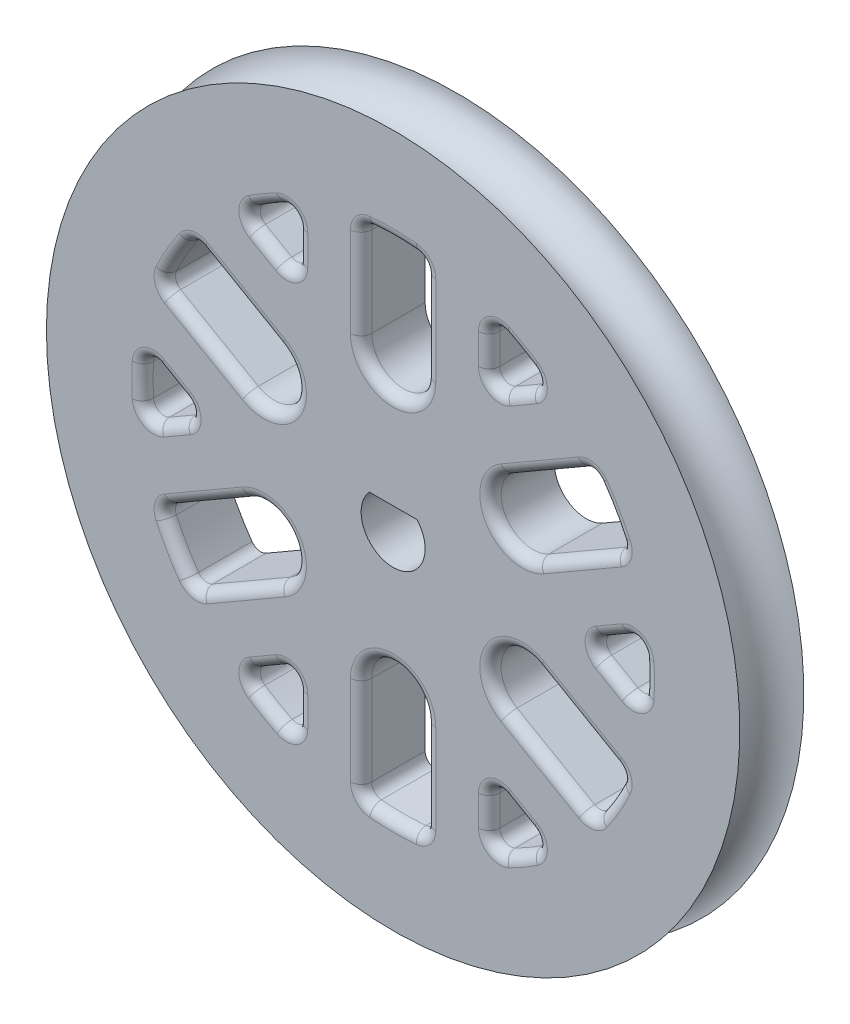
from build123d import *

# Parameters (mm, degrees)
CUT_EXTRUDE2_DEPTH       = 3
CUT_EXTRUDE1_DEPTH       = 4
FILLET2_R                = 0.5
FILLET3_R                = 0.5
CIRPATTERN1_COUNT        = 6
FILLET2_OF_CIRPATTERN1_R = 0.5
FILLET3_OF_CIRPATTERN1_R = 0.5


with BuildPart() as part:
    # Sketch3 → Revolve1 (revolve)
    with BuildSketch(Plane(origin=(0, 0, 0), x_dir=(1, 0, 0), z_dir=(0, 1, 0))):
        with BuildLine():
            Line((0, 1.5), (0, -1.5))
            Line((0, -1.5), (-16.25, -1.5))
            ThreePointArc((-16.25, -1.5), (-14.75, 0), (-16.25, 1.5))
            Line((-16.25, 1.5), (0, 1.5))
        make_face()
    revolve(axis=Axis((0, 0, -1.5), (0, 0, 1)))

    # Sketch6 → Cut-Extrude2 (cut)
    with BuildSketch(Plane.XY.offset(1.5)):
        with BuildLine():
            Line((-1.118033989, 1), (1.118033989, 1))
            ThreePointArc((1.118033989, 1), (0, -1.5), (-1.118033989, 1))
        make_face()
    extrude(amount=-CUT_EXTRUDE2_DEPTH, mode=Mode.SUBTRACT)

    # Sketch4 → Cut-Extrude1 (cut, through all)
    with BuildSketch(Plane.XY.offset(1.5)):
        with BuildLine():
            Line((-1.5, 11.653862021), (-1.5, 7))
            ThreePointArc((-1.5, 7), (0, 5.5), (1.5, 7))
            Line((1.5, 7), (1.5, 11.653862021))
            ThreePointArc((1.5, 11.653862021), (0, 11.75), (-1.5, 11.653862021))
        make_face()
        with BuildLine():
            Line((4.5, 10.854146673), (4.5, 7.794228634))
            Line((4.5, 7.794228634), (7.149966755, 9.324187654))
            ThreePointArc((7.149966755, 9.324187654), (5.875, 10.175798494), (4.5, 10.854146673))
        make_face()
    cut_extrude1 = extrude(amount=-CUT_EXTRUDE1_DEPTH, mode=Mode.SUBTRACT)

    # Fillet2
    fillet2_edges = [part.edges().sort_by_distance(p)[0] for p in [
        (-1.5, 11.653862021, 0),
        (1.5, 11.653862021, 0),
        (4.5, 10.854146673, 0),
        (7.149966755, 9.324187654, 0),
        (4.5, 7.794228634, 0),
    ]]
    fillet(fillet2_edges, radius=FILLET2_R)

    # Fillet3
    fillet3_edges = [part.edges().sort_by_distance(p)[0] for p in [
        (0, 5.5, 1.5),
        (1.5, 9.102733708, 1.5),
        (5.863825014, 8.581633373, 1.5),
        (4.5, 9.369038112, 1.5),
        (5.875, 10.175798494, 1.5),
        (0, 11.75, 1.5),
        (-1.5, 9.102733708, 1.5),
        (4.75, 8.227241336, 1.5),
        (4.736476862, 10.502740478, 1.5),
        (6.727401633, 9.353279526, 1.5),
        (1.368932394, 11.542941694, 1.5),
        (-1.368932394, 11.542941694, 1.5),
    ]]
    fillet(fillet3_edges, radius=FILLET3_R)

    # CirPattern1: Cut-Extrude1 ×6 about axis
    cirpattern1_axis = Axis((0, 0, 0), (0, 0, 1))
    for i in range(1, CIRPATTERN1_COUNT):
        add(cut_extrude1.rotate(cirpattern1_axis, i * 360 / CIRPATTERN1_COUNT), mode=Mode.SUBTRACT)

    # Fillet2 of CirPattern1
    fillet2_of_cirpattern1_edges = [part.edges().sort_by_distance(p)[0] for p in [
        (-10.842540562, 4.527892905, 0),
        (-9.342540562, 7.125969116, 0),
        (-7.149966755, 9.324187654, 0),
        (-4.5, 10.854146673, 0),
        (-4.5, 7.794228634, 0),
        (-9.342540562, -7.125969116, 0),
        (-10.842540562, -4.527892905, 0),
        (-11.649966755, -1.529959019, 0),
        (-11.649966755, 1.529959019, 0),
        (-9, 0, 0),
        (1.5, -11.653862021, 0),
        (-1.5, -11.653862021, 0),
        (-4.5, -10.854146673, 0),
        (-7.149966755, -9.324187654, 0),
        (-4.5, -7.794228634, 0),
        (10.842540562, -4.527892905, 0),
        (9.342540562, -7.125969116, 0),
        (7.149966755, -9.324187654, 0),
        (4.5, -10.854146673, 0),
        (4.5, -7.794228634, 0),
        (9.342540562, 7.125969116, 0),
        (10.842540562, 4.527892905, 0),
        (11.649966755, 1.529959019, 0),
        (11.649966755, -1.529959019, 0),
        (9, 0, 0),
    ]]
    fillet(fillet2_of_cirpattern1_edges, radius=FILLET2_OF_CIRPATTERN1_R)

    # Fillet3 of CirPattern1
    fillet3_of_cirpattern1_edges = [part.edges().sort_by_distance(p)[0] for p in [
        (-4.763139721, 2.75, 1.5),
        (-7.133198635, 5.85040496, 1.5),
        (-4.5, 9.369038112, 1.5),
        (-5.863825014, 8.581633373, 1.5),
        (-5.875, 10.175798494, 1.5),
        (-10.175798494, 5.875, 1.5),
        (-8.633198635, 3.252328748, 1.5),
        (-4.75, 8.227241336, 1.5),
        (-6.727401633, 9.353279526, 1.5),
        (-4.736476862, 10.502740478, 1.5),
        (-9.312014545, 6.957001076, 1.5),
        (-10.680946939, 4.585940618, 1.5),
        (-4.763139721, -2.75, 1.5),
        (-8.633198635, -3.252328748, 1.5),
        (-10.363825014, 0.787404739, 1.5),
        (-10.363825014, -0.787404739, 1.5),
        (-11.75, 0, 1.5),
        (-10.175798494, -5.875, 1.5),
        (-7.133198635, -5.85040496, 1.5),
        (-9.5, 0, 1.5),
        (-11.463878494, -1.149460952, 1.5),
        (-11.463878494, 1.149460952, 1.5),
        (-10.680946939, -4.585940618, 1.5),
        (-9.312014545, -6.957001076, 1.5),
        (0, -5.5, 1.5),
        (-1.5, -9.102733708, 1.5),
        (-5.863825014, -8.581633373, 1.5),
        (-4.5, -9.369038112, 1.5),
        (-5.875, -10.175798494, 1.5),
        (0, -11.75, 1.5),
        (1.5, -9.102733708, 1.5),
        (-4.75, -8.227241336, 1.5),
        (-4.736476862, -10.502740478, 1.5),
        (-6.727401633, -9.353279526, 1.5),
        (-1.368932394, -11.542941694, 1.5),
        (1.368932394, -11.542941694, 1.5),
        (4.763139721, -2.75, 1.5),
        (7.133198635, -5.85040496, 1.5),
        (4.5, -9.369038112, 1.5),
        (5.863825014, -8.581633373, 1.5),
        (5.875, -10.175798494, 1.5),
        (10.175798494, -5.875, 1.5),
        (8.633198635, -3.252328748, 1.5),
        (4.75, -8.227241336, 1.5),
        (6.727401633, -9.353279526, 1.5),
        (4.736476862, -10.502740478, 1.5),
        (9.312014545, -6.957001076, 1.5),
        (10.680946939, -4.585940618, 1.5),
        (4.763139721, 2.75, 1.5),
        (8.633198635, 3.252328748, 1.5),
        (10.363825014, -0.787404739, 1.5),
        (10.363825014, 0.787404739, 1.5),
        (11.75, 0, 1.5),
        (10.175798494, 5.875, 1.5),
        (7.133198635, 5.85040496, 1.5),
        (9.5, 0, 1.5),
        (11.463878494, 1.149460952, 1.5),
        (11.463878494, -1.149460952, 1.5),
        (10.680946939, 4.585940618, 1.5),
        (9.312014545, 6.957001076, 1.5),
    ]]
    fillet(fillet3_of_cirpattern1_edges, radius=FILLET3_OF_CIRPATTERN1_R)


solid = part.part
